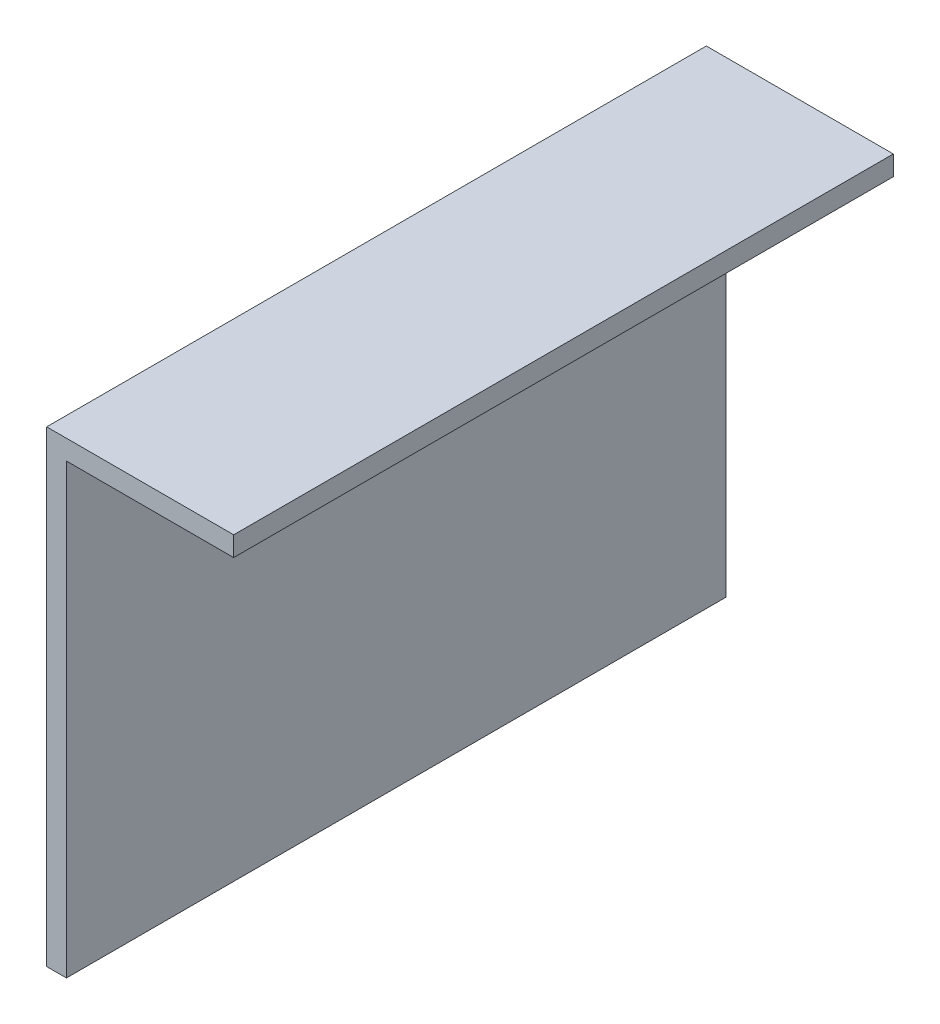
from build123d import *

# Parameters (mm, degrees)
SALIENTE_EXTRUIR1_DEPTH = 63.5


with BuildPart() as part:
    # Croquis1 → Saliente-Extruir1 (new body)
    with BuildSketch(Plane.XY):
        Polygon((0, 0), (0, 45), (18, 45), (18, 43.1), (1.9, 43.1), (1.9, 0), align=None)
    extrude(amount=SALIENTE_EXTRUIR1_DEPTH)


solid = part.part
